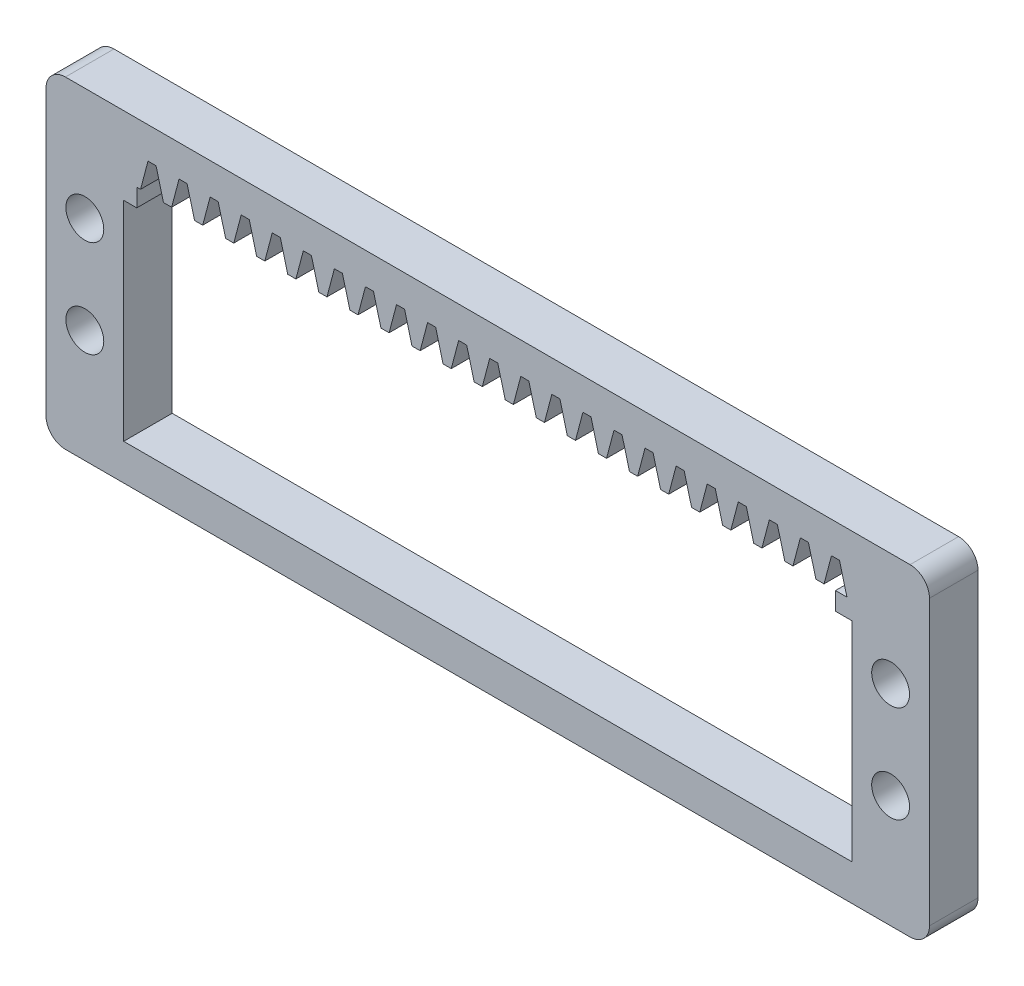
from build123d import *

# Parameters (mm, degrees)
BOSS_EXTRUDE1_DEPTH = 5
SKETCH2_W           = 75
SKETCH2_H           = 21.5
CUT_EXTRUDE1_DEPTH  = 6
SKETCH3_W           = 71.97
SKETCH3_H           = 1.85
CUT_EXTRUDE2_DEPTH  = 6
CUT_EXTRUDE4_DEPTH  = 6
LPATTERN1_COUNT     = 23
LPATTERN1_PITCH     = 3.2
SKETCH5_R           = 1.95
CUT_EXTRUDE5_DEPTH  = 10


with BuildPart() as part:
    # Sketch1 → Boss-Extrude1 (new body)
    with BuildSketch(Plane.XY):
        with BuildLine():
            Line((2, 0), (89, 0))
            ThreePointArc((89, 0), (90.414213562, -0.585786438), (91, -2))
            Line((91, -2), (91, -31.22))
            ThreePointArc((91, -31.22), (90.414213562, -32.634213562), (89, -33.22))
            Line((89, -33.22), (2, -33.22))
            ThreePointArc((2, -33.22), (0.585786438, -32.634213562), (0, -31.22))
            Line((0, -31.22), (0, -2))
            ThreePointArc((0, -2), (0.585786438, -0.585786438), (2, 0))
        make_face()
    extrude(amount=BOSS_EXTRUDE1_DEPTH)

    # Sketch2 → Cut-Extrude1 (cut, through all)
    with BuildSketch(Plane.XY.offset(5)):
        with Locations((45.5, -18.75)):
            Rectangle(SKETCH2_W, SKETCH2_H)
    extrude(amount=-CUT_EXTRUDE1_DEPTH, mode=Mode.SUBTRACT)

    # Sketch3 → Cut-Extrude2 (cut, through all)
    with BuildSketch(Plane.XY.offset(5)):
        with Locations((45.335, -7.075)):
            Rectangle(SKETCH3_W, SKETCH3_H)
    extrude(amount=-CUT_EXTRUDE2_DEPTH, mode=Mode.SUBTRACT)

    # Sketch4 → Cut-Extrude4 (cut, through all)
    with BuildSketch(Plane.XY.offset(5)):
        Polygon((81.735, -3.249176841), (82.5, -6.15), (80.14, -6.15), (80.905, -3.249176841), align=None)
    cut_extrude4 = extrude(amount=-CUT_EXTRUDE4_DEPTH, mode=Mode.SUBTRACT)

    # LPattern1: Cut-Extrude4 ×23
    with Locations(*[(-i * LPATTERN1_PITCH, 0, 0) for i in range(1, LPATTERN1_COUNT)]):
        add(cut_extrude4, mode=Mode.SUBTRACT)

    # Sketch5 → Cut-Extrude5 (cut)
    with BuildSketch(Plane.XY.offset(5)):
        with Locations((4, -11.61)):
            Circle(SKETCH5_R)
        with Locations((4, -21.61)):
            Circle(SKETCH5_R)
        with Locations((87, -11.61)):
            Circle(SKETCH5_R)
        with Locations((87, -21.61)):
            Circle(SKETCH5_R)
    extrude(amount=-CUT_EXTRUDE5_DEPTH, mode=Mode.SUBTRACT)


solid = part.part
